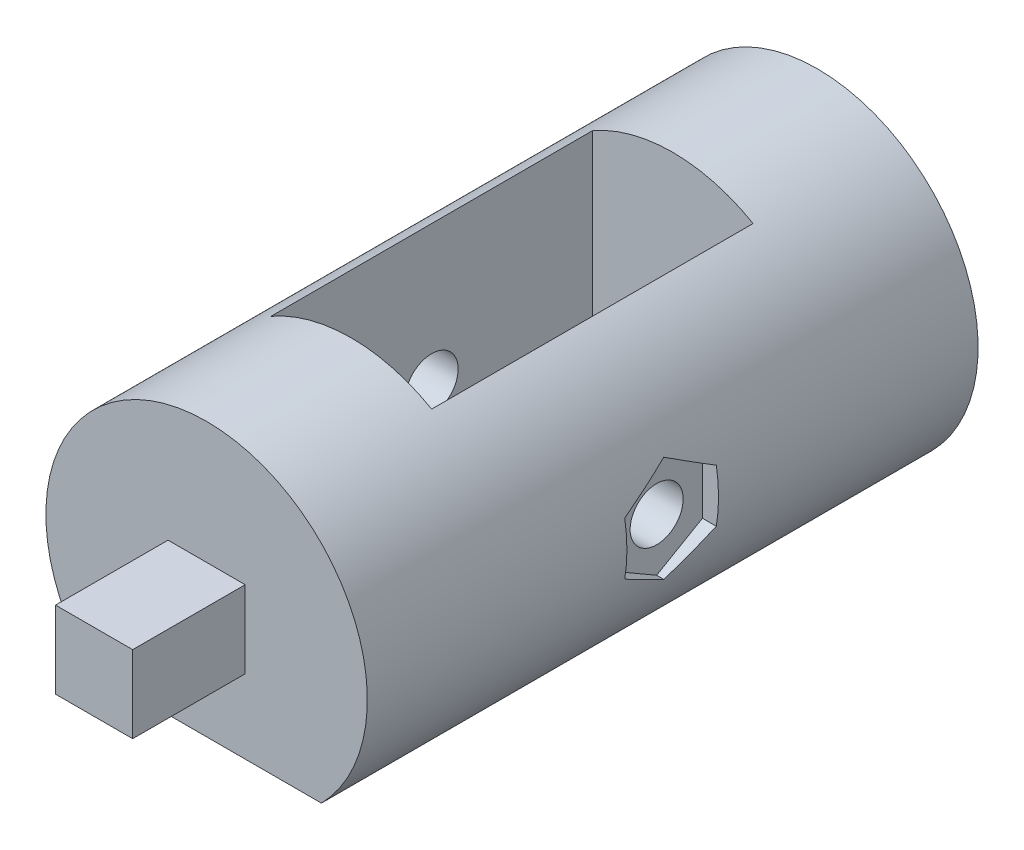
from build123d import *

# Parameters (mm, degrees)
SKIZZE1_R                            = 10
AUFSATZ_LINEAR_AUSTRAGEN1_DEPTH      = 38
SKIZZE2_W                            = 4.8
SKIZZE2_H                            = 4.8
AUFSATZ_LINEAR_AUSTRAGEN2_DEPTH      = 7
SCHNITT_LINEAR_AUSTRAGEN1_DEPTH      = 7
SKIZZE4_W                            = 20
SKIZZE4_H                            = 7
SCHNITT_LINEAR_AUSTRAGEN3_DEPTH      = 38
SCHNITT_LINEAR_AUSTRAGEN4_REACH      = 19
SKIZZE5_W                            = 10
SKIZZE5_H                            = 20
SKIZZE6_R                            = 1.65
SCHNITT_LINEAR_AUSTRAGEN5_DEPTH      = 16
SCHNITT_LINEAR_AUSTRAGEN5_DEPTH_BACK = 6
SCHNITT_LINEAR_AUSTRAGEN6_REACH      = 11
SCHNITT_LINEAR_START                 = -4
SCHNITT_LINEAR_AUSTRAGEN7_REACH      = 31
SCHNITT_LINEAR_START_2               = 14


with BuildPart() as part:
    # Skizze1 → Aufsatz-Linear austragen1 (new body)
    with BuildSketch(Plane.XY):
        Circle(SKIZZE1_R)
    extrude(amount=AUFSATZ_LINEAR_AUSTRAGEN1_DEPTH)

    # Skizze2 → Aufsatz-Linear austragen2 (add)
    with BuildSketch(Plane.XY.offset(38)):
        Rectangle(SKIZZE2_W, SKIZZE2_H)
    extrude(amount=AUFSATZ_LINEAR_AUSTRAGEN2_DEPTH)

    # Skizze3 → Schnitt-Linear austragen1 (cut)
    with BuildSketch(Plane(origin=(0, 0, 0), x_dir=(-1, 0, 0), z_dir=(0, 0, -1))):
        with BuildLine():
            Line((2.184605227, 1.5), (-2.184605227, 1.5))
            ThreePointArc((-2.184605227, 1.5), (-0.785269427, -2.530978452), (2.65, 0))
            ThreePointArc((2.65, 0), (2.530978452, 0.785269427), (2.184605227, 1.5))
        make_face()
    extrude(amount=-SCHNITT_LINEAR_AUSTRAGEN1_DEPTH, mode=Mode.SUBTRACT)

    # Skizze4 → Schnitt-Linear austragen3 (cut)
    with BuildSketch(Plane(origin=(0, 0, 0), x_dir=(-1, 0, 0), z_dir=(0, 0, -1))):
        with Locations((0, -10.5)):
            Rectangle(SKIZZE4_W, SKIZZE4_H)
    extrude(amount=-SCHNITT_LINEAR_AUSTRAGEN3_DEPTH, mode=Mode.SUBTRACT)

    # Skizze5 → Schnitt-Linear austragen4 (cut, up to next)
    with BuildSketch(Plane.XZ.offset(7), mode=Mode.PRIVATE) as schnitt_linear_austragen4_sk1:
        with Locations((0, 19)):
            Rectangle(SKIZZE5_W, SKIZZE5_H)
    schnitt_linear_austragen4_tool1 = extrude(schnitt_linear_austragen4_sk1.sketch, amount=-SCHNITT_LINEAR_AUSTRAGEN4_REACH, mode=Mode.PRIVATE) & part.part
    add(schnitt_linear_austragen4_tool1.solids().sort_by_distance((0, -7, 19))[0], mode=Mode.SUBTRACT)

    # Skizze6 → Schnitt-Linear austragen5 (cut, two sides)
    with BuildSketch(Plane.ZY.offset(-5)) as schnitt_linear_austragen5_sk:
        with Locations((19, 0)):
            Circle(SKIZZE6_R)
    extrude(amount=SCHNITT_LINEAR_AUSTRAGEN5_DEPTH, mode=Mode.SUBTRACT)
    extrude(schnitt_linear_austragen5_sk.sketch, amount=-SCHNITT_LINEAR_AUSTRAGEN5_DEPTH_BACK, mode=Mode.SUBTRACT)

    # Skizze7 → Schnitt-Linear austragen6 (cut, up to next)
    with BuildSketch(Plane.ZY.offset(-5).offset(SCHNITT_LINEAR_START), mode=Mode.PRIVATE) as schnitt_linear_austragen6_sk1:
        Polygon((19, -3.290896534), (21.85, -1.645448267), (21.85, 1.645448267), (19, 3.290896534), (16.15, 1.645448267), (16.15, -1.645448267), align=None)
    schnitt_linear_austragen6_tool1 = extrude(schnitt_linear_austragen6_sk1.sketch, amount=-SCHNITT_LINEAR_AUSTRAGEN6_REACH, mode=Mode.PRIVATE) & part.part
    add(schnitt_linear_austragen6_tool1.solids().sort_by_distance((9, 0, 19))[0], mode=Mode.SUBTRACT)

    # Skizze7_2 → Schnitt-Linear austragen7 (cut, up to next)
    with BuildSketch(Plane.ZY.offset(-5).offset(SCHNITT_LINEAR_START_2), mode=Mode.PRIVATE) as schnitt_linear_austragen7_sk1:
        Polygon((19, -3.290896534), (21.85, -1.645448267), (21.85, 1.645448267), (19, 3.290896534), (16.15, 1.645448267), (16.15, -1.645448267), align=None)
    schnitt_linear_austragen7_tool1 = extrude(schnitt_linear_austragen7_sk1.sketch, amount=SCHNITT_LINEAR_AUSTRAGEN7_REACH, mode=Mode.PRIVATE) & part.part
    add(schnitt_linear_austragen7_tool1.solids().sort_by_distance((-9, 0, 19))[0], mode=Mode.SUBTRACT)


solid = part.part
